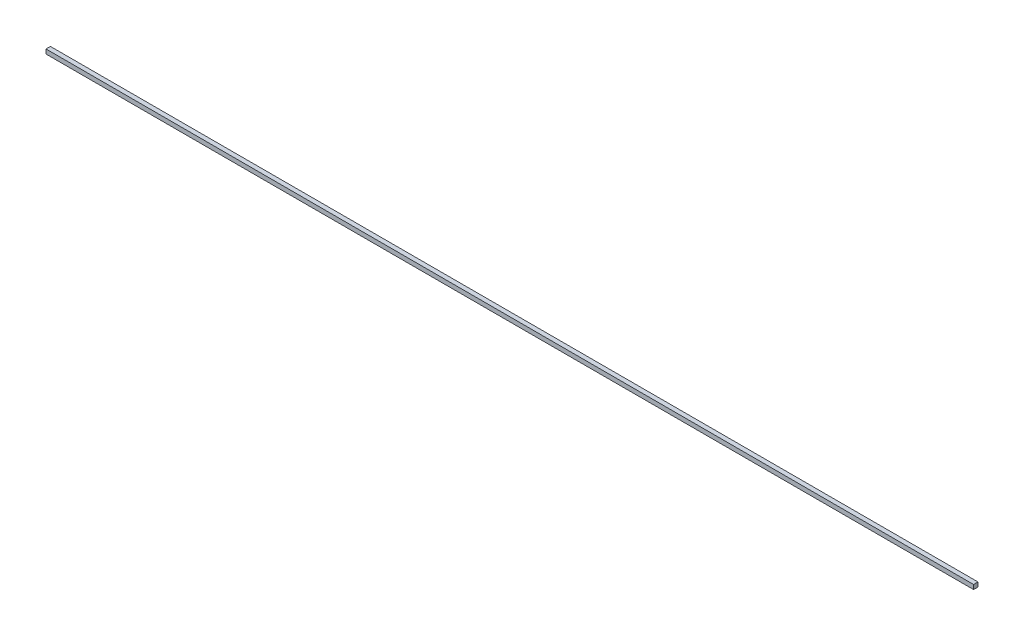
from build123d import *

# Parameters (mm, degrees)
SKETCH2_W           = 1333.5
SKETCH2_H           = 6.35
BOSS_EXTRUDE2_DEPTH = 6.35


with BuildPart() as part:
    # Sketch2 → Boss-Extrude2 (new body)
    with BuildSketch(Plane(origin=(0, 0, 0), x_dir=(1, 0, 0), z_dir=(0, 1, 0))):
        Rectangle(SKETCH2_W, SKETCH2_H)
    extrude(amount=BOSS_EXTRUDE2_DEPTH)


solid = part.part
